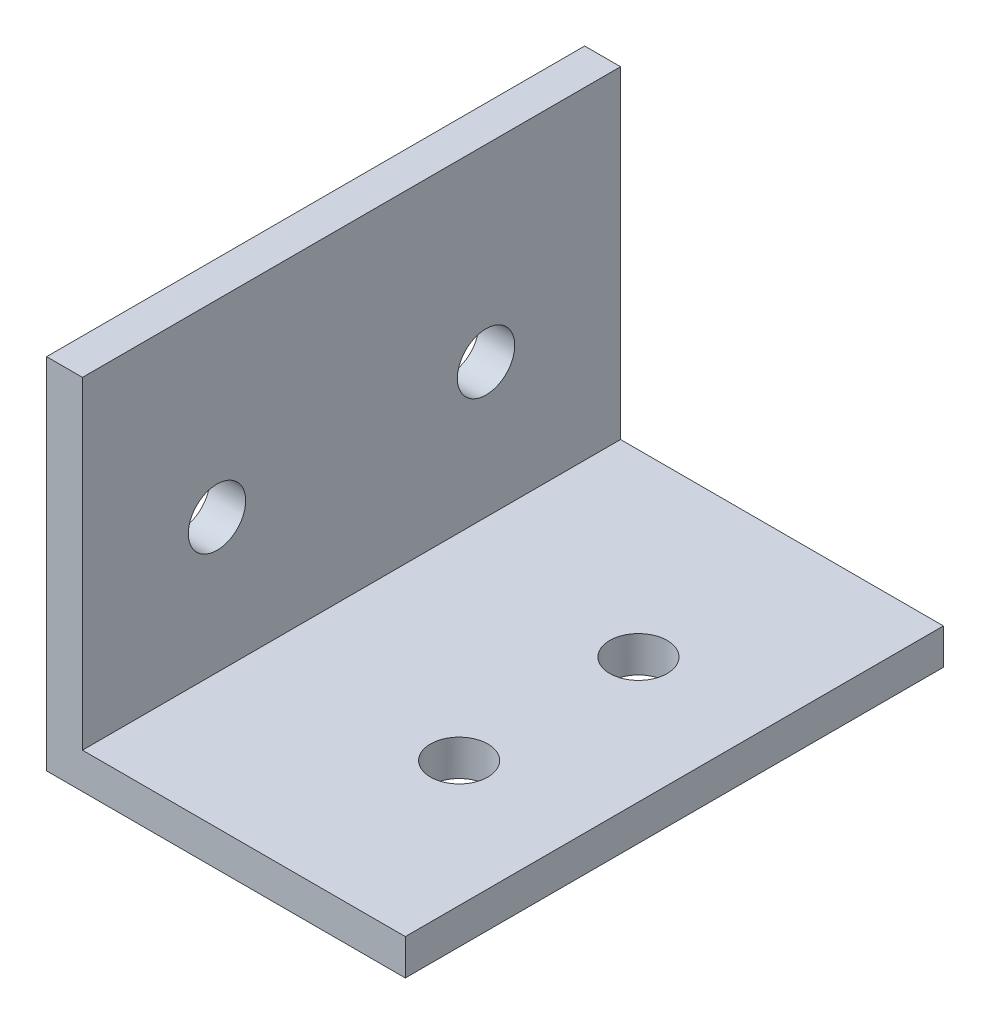
from build123d import *

# Parameters (mm, degrees)
BOSS_EXTRUDE1_DEPTH = 30
SKETCH2_R           = 1.6
CUT_EXTRUDE1_DEPTH  = 10
SKETCH3_R           = 1.6
CUT_EXTRUDE2_DEPTH  = 4


with BuildPart() as part:
    # Sketch1 → Boss-Extrude1 (new body)
    with BuildSketch(Plane.XY):
        Polygon((0, 20), (0, 0), (20, 0), (20, 2), (2, 2), (2, 20), align=None)
    extrude(amount=BOSS_EXTRUDE1_DEPTH)

    # Sketch2 → Cut-Extrude1 (cut)
    with BuildSketch(Plane(origin=(0, 0, 0), x_dir=(0, 0, -1), z_dir=(1, 0, 0))):
        with Locations((-22.5, 9.5)):
            Circle(SKETCH2_R)
        with Locations((-7.5, 9.5)):
            Circle(SKETCH2_R)
    extrude(amount=CUT_EXTRUDE1_DEPTH, mode=Mode.SUBTRACT)

    # Sketch3 → Cut-Extrude2 (cut)
    with BuildSketch(Plane(origin=(0, 0, 0), x_dir=(1, 0, 0), z_dir=(0, 1, 0))):
        with Locations((13, -10)):
            Circle(SKETCH3_R)
        with Locations((13, -20)):
            Circle(SKETCH3_R)
    extrude(amount=CUT_EXTRUDE2_DEPTH, mode=Mode.SUBTRACT)


solid = part.part
